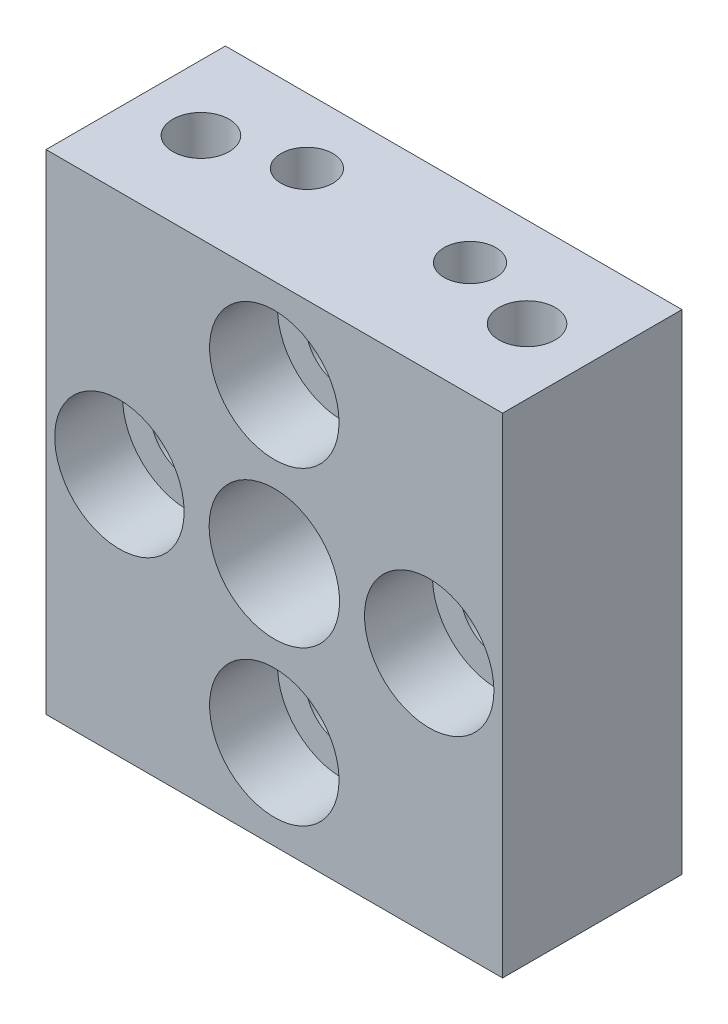
from build123d import *

# Parameters (mm, degrees)
SKETCH1_W                                      = 28
SKETCH1_H                                      = 30
BOSS_EXTRUDE1_DEPTH                            = 11
CBORE_FOR_8_SOCKET_HEAD_CAP_SCREW3_D           = 4.4958
CBORE_FOR_8_SOCKET_HEAD_CAP_SCREW3_DEPTH       = 11
CBORE_FOR_8_SOCKET_HEAD_CAP_SCREW3_CBORE_D     = 7.9375
CBORE_FOR_8_SOCKET_HEAD_CAP_SCREW3_CBORE_DEPTH = 4.1656
F_8_32_TAPPED_HOLE1_AT_2_COUNT                 = 2
F_8_32_TAPPED_HOLE1_AT_2_PITCH                 = 20
F_1_8_0_1250_DOWEL_HOLE1_AT_2_COUNT            = 2
F_1_8_0_1250_DOWEL_HOLE1_AT_2_PITCH            = 10


with BuildPart() as part:
    # Sketch1 → Boss-Extrude1 (new body)
    with BuildSketch(Plane.XY):
        with Locations((14, 0)):
            Rectangle(SKETCH1_W, SKETCH1_H)
    extrude(amount=BOSS_EXTRUDE1_DEPTH)

    # Sketch16 → CBORE for M5 Hex Head Bolt1 (revolve, cut)
    with BuildSketch(Plane.YZ.offset(14)):
        Polygon((0, 0), (0, 11), (4, 11), (4, 3.25), (4.25, 3), (5.5, 3), (5.5, 1), (6.5, 0), align=None)
    revolve(axis=Axis((14, 0, -6.35), (0, 0, 1)), mode=Mode.SUBTRACT)

    # CBORE for #8 Socket Head Cap Screw3
    with Locations(Plane.XY.offset(11)):
        with Locations((23.5, 0), (4.5, 0), (14, 9.5), (14, -9.5)):
            CounterBoreHole(CBORE_FOR_8_SOCKET_HEAD_CAP_SCREW3_D / 2, CBORE_FOR_8_SOCKET_HEAD_CAP_SCREW3_CBORE_D / 2, CBORE_FOR_8_SOCKET_HEAD_CAP_SCREW3_CBORE_DEPTH, depth=CBORE_FOR_8_SOCKET_HEAD_CAP_SCREW3_DEPTH)

    # Sketch13 → #8-32 Tapped Hole1 (revolve, cut)
    with BuildSketch(Plane(origin=(4, 15, 5.5), x_dir=(0, 0, 1), z_dir=(1, 0, 0))):
        Polygon((0, 0), (0, 11.037806461), (1.7272, 10), (1.7272, 0), align=None)
    f_8_32_tapped_hole1 = revolve(axis=Axis((4, 21.35, 5.5), (0, -1, 0)), mode=Mode.SUBTRACT)

    # #8-32 Tapped Hole1 at 2: #8-32 Tapped Hole1 ×2
    with Locations(*[(i * F_8_32_TAPPED_HOLE1_AT_2_PITCH, 0, 0) for i in range(1, F_8_32_TAPPED_HOLE1_AT_2_COUNT)]):
        add(f_8_32_tapped_hole1, mode=Mode.SUBTRACT)

    # Sketch20 → 1/8 (0.1250) Dowel Hole1 (revolve, cut)
    with BuildSketch(Plane(origin=(9, 15, 4), x_dir=(0, 0, 1), z_dir=(1, 0, 0))):
        Polygon((0, 0), (0, 5.953866233), (1.5875, 5), (1.5875, 0), align=None)
    f_1_8_0_1250_dowel_hole1 = revolve(axis=Axis((9, 21.35, 4), (0, -1, 0)), mode=Mode.SUBTRACT)

    # 1/8 (0.1250) Dowel Hole1 at 2: 1/8 (0.1250) Dowel Hole1 ×2
    with Locations(*[(i * F_1_8_0_1250_DOWEL_HOLE1_AT_2_PITCH, 0, 0) for i in range(1, F_1_8_0_1250_DOWEL_HOLE1_AT_2_COUNT)]):
        add(f_1_8_0_1250_dowel_hole1, mode=Mode.SUBTRACT)

    # Mirror1: 1/8 (0.1250) Dowel Hole1, #8-32 Tapped Hole1 across plane
    add(f_1_8_0_1250_dowel_hole1.mirror(Plane.ZX), mode=Mode.SUBTRACT)
    add(f_8_32_tapped_hole1.mirror(Plane.ZX), mode=Mode.SUBTRACT)

    # Mirror1 copy 1 sketch → Mirror1 copy 1 (revolve, cut)
    with BuildSketch(Plane(origin=(19, -15, 4), x_dir=(0, 0, 1), z_dir=(1, 0, 0))):
        Polygon((0, 0), (0, -5.953866233), (1.5875, -5), (1.5875, 0), align=None)
    revolve(axis=Axis((19, -21.35, 4), (0, -1, 0)), mode=Mode.SUBTRACT)

    # Mirror1 copy 2 sketch → Mirror1 copy 2 (revolve, cut)
    with BuildSketch(Plane(origin=(24, -15, 5.5), x_dir=(0, 0, 1), z_dir=(1, 0, 0))):
        Polygon((0, 0), (0, -11.037806461), (1.7272, -10), (1.7272, 0), align=None)
    revolve(axis=Axis((24, -21.35, 5.5), (0, -1, 0)), mode=Mode.SUBTRACT)


solid = part.part
